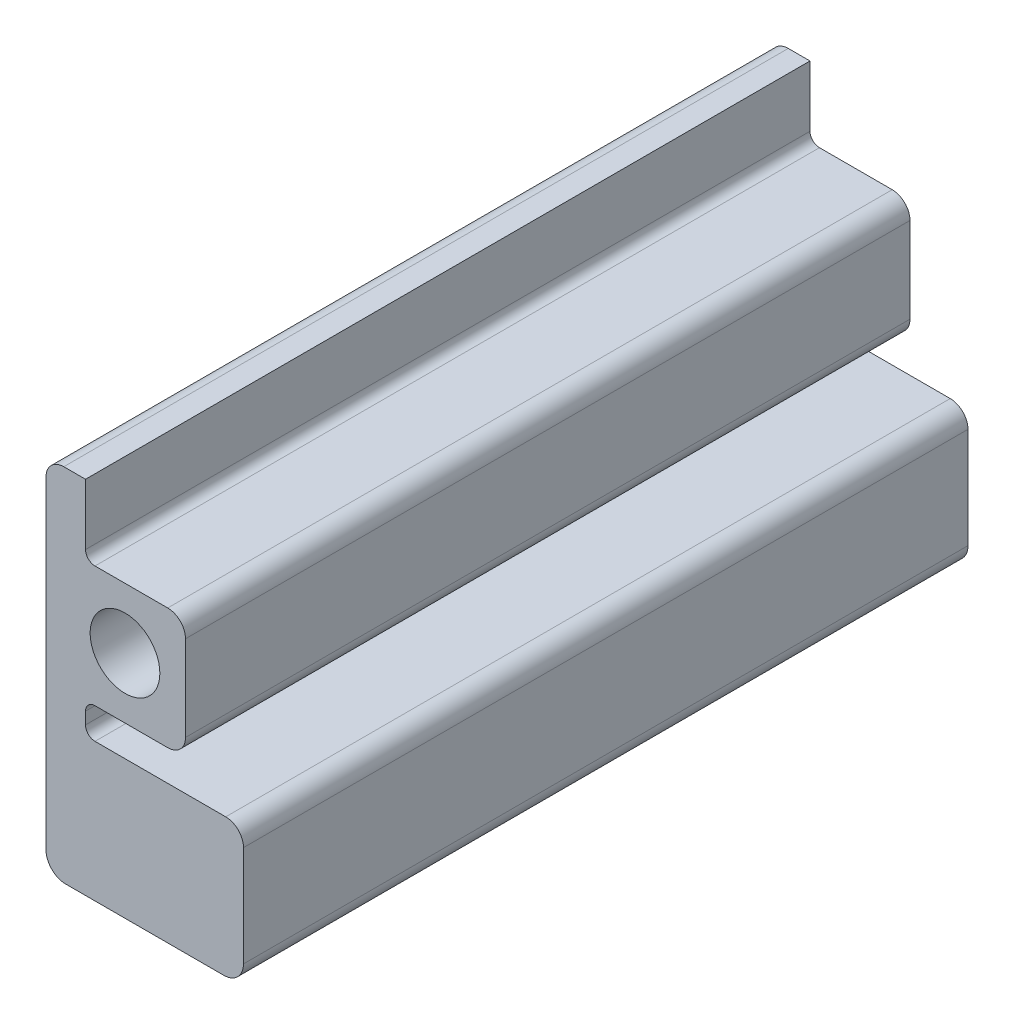
from build123d import *

# Parameters (mm, degrees)
SKETCH1_R           = 11.2
BOSS_EXTRUDE1_DEPTH = 232.947291788
CUT_EXTRUDE1_DEPTH  = 236.982


with BuildPart() as part:
    # Sketch1 → Boss-Extrude1 (new body)
    with BuildSketch(Plane.XY):
        with BuildLine():
            Line((-25.4, -67.479999962), (-25.4, 36.365))
            ThreePointArc((-25.4, 36.365), (-23.726115254, 40.406115254), (-19.685, 42.08))
            Line((-19.685, 42.08), (32.385, 42.08))
            ThreePointArc((32.385, 42.08), (36.426115254, 40.406115254), (38.1, 36.365))
            Line((38.1, 36.365), (38.1, 35.095))
            ThreePointArc((38.1, 35.095), (36.426115254, 31.053884746), (32.385, 29.38))
            Line((32.385, 29.38), (-9.652, 29.38))
            ThreePointArc((-9.652, 29.38), (-11.807261469, 28.487261469), (-12.7, 26.332))
            Line((-12.7, 26.332), (-12.7, 22.503))
            ThreePointArc((-12.7, 22.503), (-11.807261469, 20.347738531), (-9.652, 19.455))
            Line((-9.652, 19.455), (0, 19.455))
            Line((0, 19.455), (13.74, 19.455))
            ThreePointArc((13.74, 19.455), (17.781115254, 17.781115254), (19.455, 13.74))
            Line((19.455, 13.74), (19.455, 0))
            Line((19.455, 0), (19.455, -13.74))
            ThreePointArc((19.455, -13.74), (17.781115254, -17.781115254), (13.74, -19.455))
            Line((13.74, -19.455), (0, -19.455))
            Line((0, -19.455), (-9.652, -19.455))
            ThreePointArc((-9.652, -19.455), (-11.807261469, -20.347738531), (-12.7, -22.503))
            Line((-12.7, -22.503), (-12.7, -26.331999962))
            ThreePointArc((-12.7, -26.331999962), (-11.807261469, -28.487261431), (-9.652, -29.379999962))
            Line((-9.652, -29.379999962), (32.385, -29.379999962))
            ThreePointArc((32.385, -29.379999962), (36.426115254, -31.053884708), (38.1, -35.094999962))
            Line((38.1, -35.094999962), (38.1, -67.479999962))
            ThreePointArc((38.1, -67.479999962), (36.240128061, -71.970128023), (31.75, -73.829999962))
            Line((31.75, -73.829999962), (-19.05, -73.829999962))
            ThreePointArc((-19.05, -73.829999962), (-23.540128061, -71.970128023), (-25.4, -67.479999962))
        make_face()
        Circle(SKETCH1_R, mode=Mode.SUBTRACT)
    extrude(amount=BOSS_EXTRUDE1_DEPTH)

    # Sketch2 → Cut-Extrude1 (cut)
    with BuildSketch(Plane.XY.offset(232.947291788)):
        Polygon((19.455, -13.74), (38.1, -13.74), (38.1, 42.08), (19.455, 42.08), (-12.7, 42.08), (-12.7, 22.503), (19.455, 22.503), align=None)
    extrude(amount=-CUT_EXTRUDE1_DEPTH, mode=Mode.SUBTRACT)


solid = part.part
